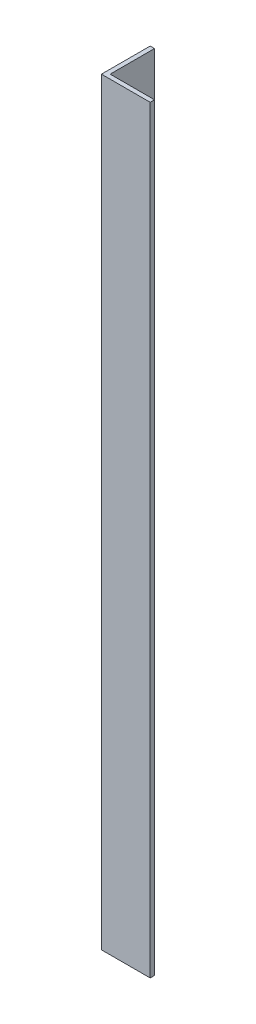
from build123d import *

# Parameters (mm, degrees)
EXTRUDE_1_DEPTH = 700


with BuildPart() as part:
    # Эскиз1 → Вытянуть-Тонкостенный1 (new body)
    with BuildSketch(Plane(origin=(0, 0, 0), x_dir=(1, 0, 0), z_dir=(0, 1, 0))):
        Polygon((0, 45), (0, 0), (45, 0), (45, 4), (4, 4), (4, 45), align=None)
    extrude(amount=EXTRUDE_1_DEPTH)


solid = part.part
